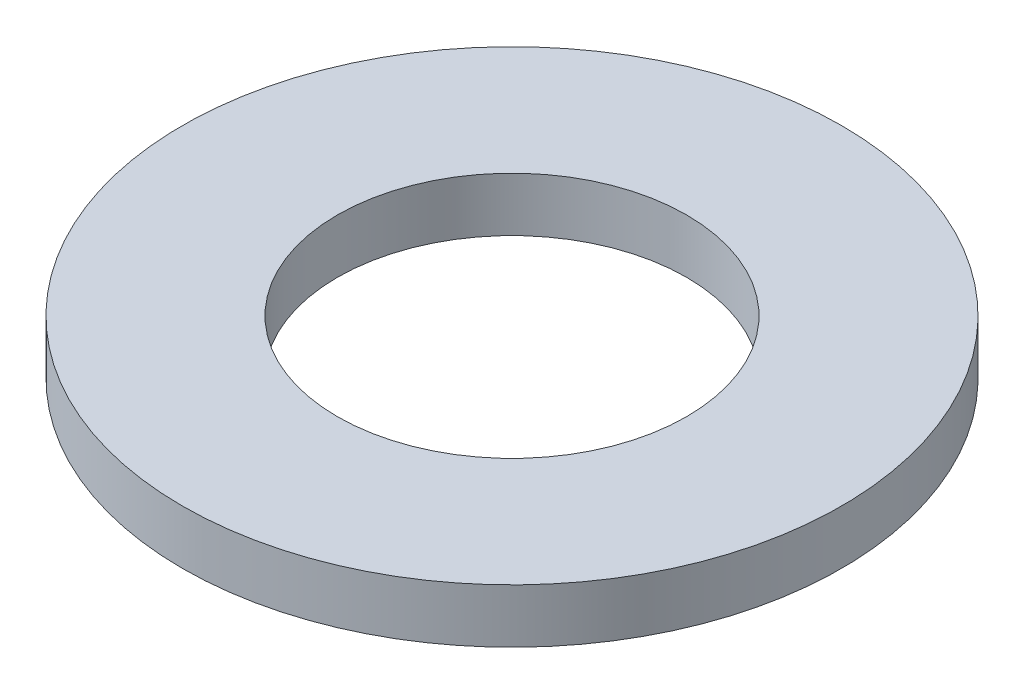
from build123d import *

# Parameters (mm, degrees)
SKETCH1_R           = 6.35
BOSS_EXTRUDE1_DEPTH = 1.0414
SKETCH5_R           = 3.3655
CUT_EXTRUDE1_DEPTH  = 2.0414


with BuildPart() as part:
    # Sketch1 → Boss-Extrude1 (new body)
    with BuildSketch(Plane(origin=(0, 0, 0), x_dir=(1, 0, 0), z_dir=(0, 1, 0))):
        Circle(SKETCH1_R)
    extrude(amount=BOSS_EXTRUDE1_DEPTH)

    # Sketch5 → Cut-Extrude1 (cut, through all)
    with BuildSketch(Plane(origin=(0, 1.0414, 0), x_dir=(-1, 0, 0), z_dir=(0, 1, 0))):
        Circle(SKETCH5_R)
    extrude(amount=-CUT_EXTRUDE1_DEPTH, mode=Mode.SUBTRACT)


solid = part.part
